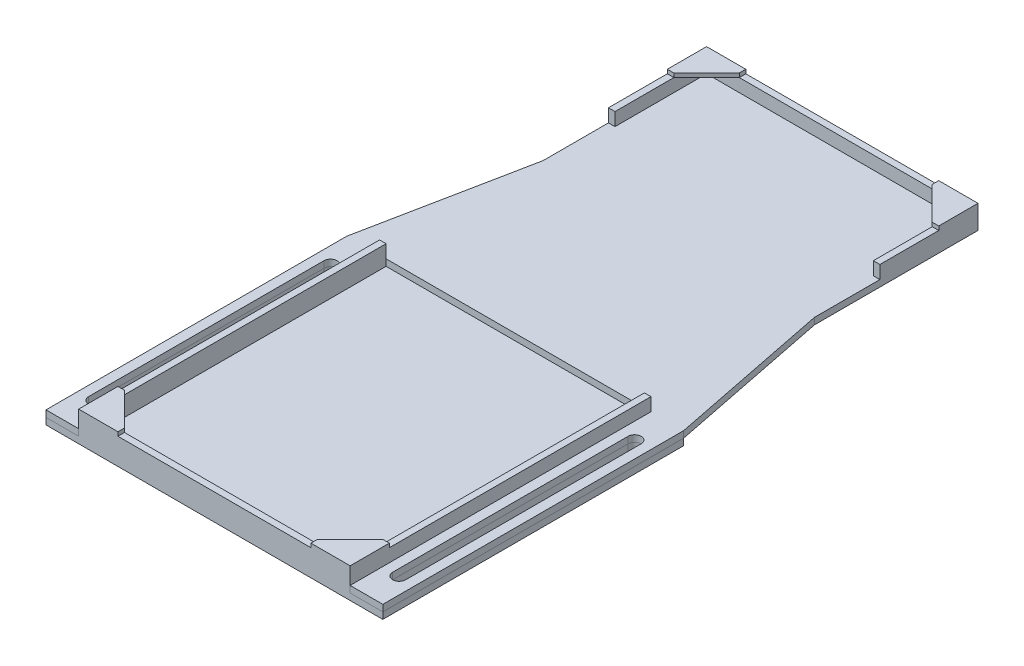
from build123d import *

# Parameters (mm, degrees)
CROQUIS1_W              = 20
CROQUIS1_H              = 20
CROQUIS1_R              = 3
SALIENTE_EXTRUIR1_DEPTH = 5
SALIENTE_EXTRUIR2_DEPTH = 2
SALIENTE_EXTRUIR3_DEPTH = 8
SALIENTE_EXTRUIR4_DEPTH = 1.2
CROQUIS5_W              = 10
CROQUIS5_H              = 92
SALIENTE_EXTRUIR5_DEPTH = 2
CROQUIS6_W              = 83
CROQUIS6_H              = 100
CROQUIS6_W_2            = 10
CROQUIS6_H_2            = 92
SALIENTE_EXTRUIR6_DEPTH = 2
SALIENTE_EXTRUIR7_DEPTH = 4
SALIENTE_EXTRUIR8_DEPTH = 1.2


with BuildPart() as part:
    # Croquis1 → Saliente-Extruir1 (new body)
    with BuildSketch(Plane(origin=(0, 0, 0), x_dir=(1, 0, 0), z_dir=(0, 1, 0))):
        Rectangle(CROQUIS1_W, CROQUIS1_H)
        Circle(CROQUIS1_R, mode=Mode.SUBTRACT)
        with BuildLine():
            Line((2.321637353, -1.9), (-2.321637353, -1.9))
            ThreePointArc((-2.321637353, -1.9), (0, -3), (2.321637353, -1.9))
        make_face()
        with BuildLine():
            Line((-2.321637353, 1.9), (2.321637353, 1.9))
            ThreePointArc((2.321637353, 1.9), (0, 3), (-2.321637353, 1.9))
        make_face()
    extrude(amount=SALIENTE_EXTRUIR1_DEPTH)

    # Croquis2 → Saliente-Extruir2 (add)
    with BuildSketch(Plane(origin=(0, 5, 0), x_dir=(1, 0, 0), z_dir=(0, 1, 0))):
        Polygon((-10, 10), (-39.5, 10), (-39.5, 0), (-39.5, -80), (39.5, -80), (39.5, 0), (39.5, 10), (10, 10), align=None)
    extrude(amount=SALIENTE_EXTRUIR2_DEPTH)

    # Croquis3 → Saliente-Extruir3 (add)
    with BuildSketch(Plane.XZ.offset(-5)):
        Polygon((39.5, 80), (39.5, -10), (41.5, -10), (41.5, 82), (-41.5, 82), (-41.5, -10), (-39.5, -10), (-39.5, 80), align=None)
    extrude(amount=-SALIENTE_EXTRUIR3_DEPTH)

    # Croquis4 → Saliente-Extruir4 (add)
    with BuildSketch(Plane(origin=(0, 13, 0), x_dir=(1, 0, 0), z_dir=(0, 1, 0))):
        Polygon((-39.5, -80), (-29.5, -80), (-39.5, -70), align=None)
        Polygon((-29.5, -82), (-29.5, -80), (-39.5, -80), (-39.5, -70), (-41.5, -70), (-41.5, -82), align=None)
        Polygon((39.5, -70), (29.5, -80), (39.5, -80), align=None)
        Polygon((39.5, -80), (29.5, -80), (29.5, -82), (41.5, -82), (41.5, -70), (39.5, -70), align=None)
    extrude(amount=SALIENTE_EXTRUIR4_DEPTH)

    # Croquis5 → Saliente-Extruir5 (add)
    with BuildSketch(Plane.XZ.offset(-5)):
        with Locations((-46.5, 36)):
            Rectangle(CROQUIS5_W, CROQUIS5_H)
        with BuildLine():
            Line((-48.5, 0), (-48.5, 72))
            ThreePointArc((-48.5, 72), (-46.5, 74), (-44.5, 72))
            Line((-44.5, 72), (-44.5, 0))
            ThreePointArc((-44.5, 0), (-46.5, -2), (-48.5, 0))
        make_face(mode=Mode.SUBTRACT)
        with Locations((46.5, 36)):
            Rectangle(CROQUIS5_W, CROQUIS5_H)
        with BuildLine():
            Line((48.5, 0), (48.5, 72))
            ThreePointArc((48.5, 72), (46.5, 74), (44.5, 72))
            Line((44.5, 72), (44.5, 0))
            ThreePointArc((44.5, 0), (46.5, -2), (48.5, 0))
        make_face(mode=Mode.SUBTRACT)
    extrude(amount=-SALIENTE_EXTRUIR5_DEPTH)


with BuildPart() as body_2:
    # Croquis6 → Saliente-Extruir6 (new body)
    with BuildSketch(Plane(origin=(0, 7, 0), x_dir=(1, 0, 0), z_dir=(0, 1, 0))):
        with Locations((0, 60)):
            Rectangle(CROQUIS6_W, CROQUIS6_H)
        Polygon((-51.5, 10), (-41.5, 10), (-41.5, 60), align=None)
        Polygon((41.5, 60), (41.5, 10), (51.5, 10), align=None)
        with Locations((46.5, -36)):
            Rectangle(CROQUIS6_W_2, CROQUIS6_H_2)
        with BuildLine():
            Line((44.5, -72), (44.5, 0))
            ThreePointArc((44.5, 0), (46.5, 2), (48.5, 0))
            Line((48.5, 0), (48.5, -72))
            ThreePointArc((48.5, -72), (46.5, -74), (44.5, -72))
        make_face(mode=Mode.SUBTRACT)
        with Locations((-46.5, -36)):
            Rectangle(CROQUIS6_W_2, CROQUIS6_H_2)
        with BuildLine():
            ThreePointArc((-44.5, 0), (-46.5, 2), (-48.5, 0))
            Line((-48.5, 0), (-48.5, -72))
            ThreePointArc((-48.5, -72), (-46.5, -74), (-44.5, -72))
            Line((-44.5, -72), (-44.5, 0))
        make_face(mode=Mode.SUBTRACT)
    extrude(amount=SALIENTE_EXTRUIR6_DEPTH)

    # Croquis7 → Saliente-Extruir7 (add)
    with BuildSketch(Plane(origin=(0, 9, 0), x_dir=(1, 0, 0), z_dir=(0, 1, 0))):
        Polygon((-39.5, 80), (-39.5, 108), (39.5, 108), (39.5, 80), (41.5, 80), (41.5, 110), (-41.5, 110), (-41.5, 80), align=None)
    extrude(amount=SALIENTE_EXTRUIR7_DEPTH)

    # Croquis8 → Saliente-Extruir8 (add)
    with BuildSketch(Plane(origin=(0, 13, 0), x_dir=(1, 0, 0), z_dir=(0, 1, 0))):
        Polygon((-39.5, 98), (-29.5, 108), (-29.5, 110), (-41.5, 110), (-41.5, 98), align=None)
        Polygon((29.5, 108), (39.5, 98), (41.5, 98), (41.5, 110), (29.5, 110), align=None)
    extrude(amount=SALIENTE_EXTRUIR8_DEPTH)


solid = Compound([part.part, body_2.part])
